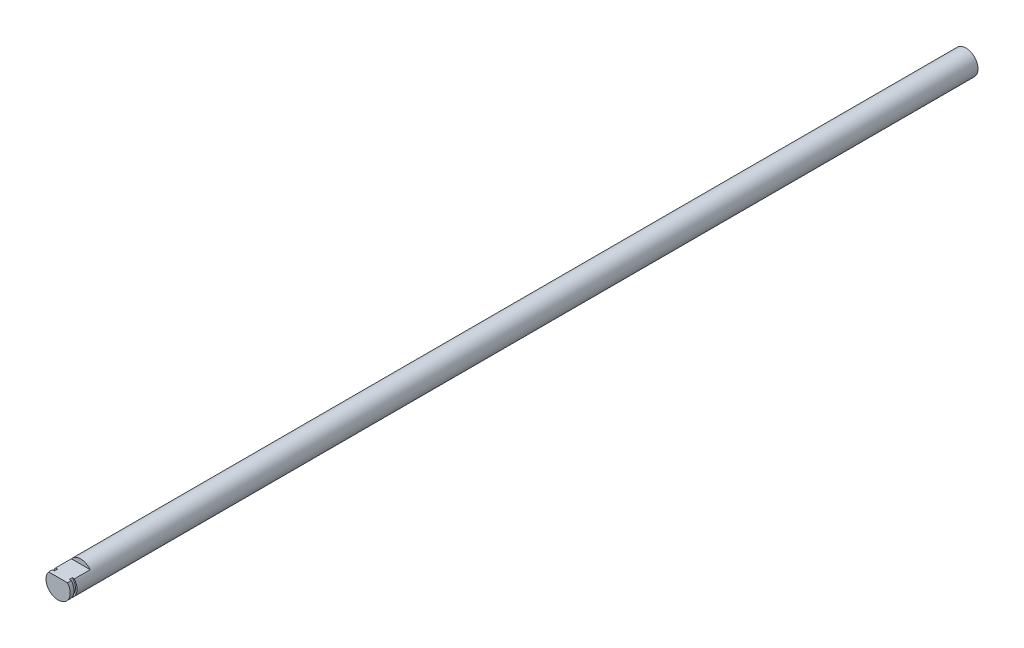
from build123d import *

# Parameters (mm, degrees)
SKETCH1_R           = 4
BOSS_EXTRUDE1_DEPTH = 325
CUT_EXTRUDE1_DEPTH  = 7.5
SKETCH3_R           = 4
SKETCH3_R_2         = 3.5
CUT_EXTRUDE2_DEPTH  = 1
SKETCH5_R           = 4
CUT_EXTRUDE3_DEPTH  = 65
SKETCH6_R           = 4
BOSS_EXTRUDE2_DEPTH = 13
SKETCH7_R           = 4
BOSS_EXTRUDE3_DEPTH = 10
SKETCH8_R           = 4
BOSS_EXTRUDE4_DEPTH = 40
SKETCH9_R           = 4
CUT_EXTRUDE4_DEPTH  = 30
SKETCH10_R          = 4
CUT_EXTRUDE5_DEPTH  = 61
SKETCH11_R          = 4
BOSS_EXTRUDE5_DEPTH = 68


with BuildPart() as part:
    # Sketch1 → Boss-Extrude1 (new body)
    with BuildSketch(Plane.XY):
        Circle(SKETCH1_R)
    extrude(amount=BOSS_EXTRUDE1_DEPTH)

    # Sketch2 → Cut-Extrude1 (cut)
    with BuildSketch(Plane.XY.offset(325)):
        with BuildLine():
            Line((3.122498999, 2.5), (-3.122498999, 2.5))
            ThreePointArc((-3.122498999, 2.5), (0, 4), (3.122498999, 2.5))
        make_face()
    extrude(amount=-CUT_EXTRUDE1_DEPTH, mode=Mode.SUBTRACT)

    # Sketch3 → Cut-Extrude2 (cut)
    with BuildSketch(Plane.XY.offset(323.75)):
        Circle(SKETCH3_R)
        Circle(SKETCH3_R_2, mode=Mode.SUBTRACT)
    extrude(amount=-CUT_EXTRUDE2_DEPTH, mode=Mode.SUBTRACT)

    # Sketch5 → Cut-Extrude3 (cut)
    with BuildSketch(Plane(origin=(0, 0, 0), x_dir=(-1, 0, 0), z_dir=(0, 0, -1))):
        Circle(SKETCH5_R)
    extrude(amount=-CUT_EXTRUDE3_DEPTH, mode=Mode.SUBTRACT)

    # Sketch6 → Boss-Extrude2 (add)
    with BuildSketch(Plane(origin=(0, 0, 65), x_dir=(-1, 0, 0), z_dir=(0, 0, -1))):
        Circle(SKETCH6_R)
    extrude(amount=BOSS_EXTRUDE2_DEPTH)

    # Sketch7 → Boss-Extrude3 (add)
    with BuildSketch(Plane(origin=(0, 0, 52), x_dir=(-1, 0, 0), z_dir=(0, 0, -1))):
        Circle(SKETCH7_R)
    extrude(amount=BOSS_EXTRUDE3_DEPTH)

    # Sketch8 → Boss-Extrude4 (add)
    with BuildSketch(Plane(origin=(0, 0, 42), x_dir=(-1, 0, 0), z_dir=(0, 0, -1))):
        Circle(SKETCH8_R)
    extrude(amount=BOSS_EXTRUDE4_DEPTH)

    # Sketch9 → Cut-Extrude4 (cut)
    with BuildSketch(Plane(origin=(0, 0, 2), x_dir=(-1, 0, 0), z_dir=(0, 0, -1))):
        Circle(SKETCH9_R)
    extrude(amount=-CUT_EXTRUDE4_DEPTH, mode=Mode.SUBTRACT)

    # Sketch10 → Cut-Extrude5 (cut)
    with BuildSketch(Plane(origin=(0, 0, 32), x_dir=(-1, 0, 0), z_dir=(0, 0, -1))):
        Circle(SKETCH10_R)
    extrude(amount=-CUT_EXTRUDE5_DEPTH, mode=Mode.SUBTRACT)

    # Sketch11 → Boss-Extrude5 (add)
    with BuildSketch(Plane(origin=(0, 0, 93), x_dir=(-1, 0, 0), z_dir=(0, 0, -1))):
        Circle(SKETCH11_R)
    extrude(amount=BOSS_EXTRUDE5_DEPTH)


solid = part.part
